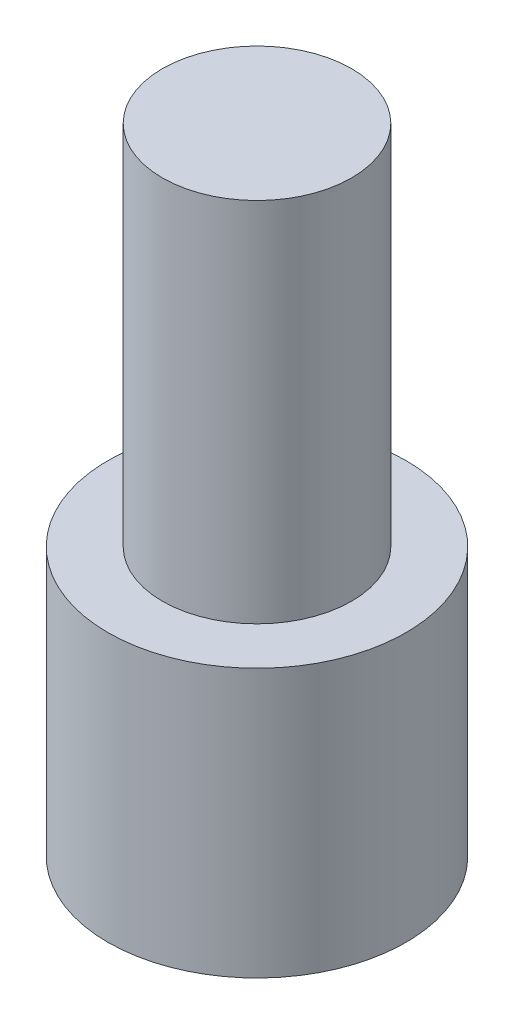
from build123d import *

# Parameters (mm, degrees)
SKETCH_1_R      = 5
EXTRUDE_1_DEPTH = 9
SKETCH_2_R      = 3.175
EXTRUDE_2_DEPTH = 12.3


with BuildPart() as part:
    # Эскиз1 → Бобышка-Вытянуть1 (new body)
    with BuildSketch(Plane(origin=(0, 0, 0), x_dir=(1, 0, 0), z_dir=(0, 1, 0))):
        Circle(SKETCH_1_R)
    extrude(amount=EXTRUDE_1_DEPTH)

    # Эскиз2 → Бобышка-Вытянуть2 (add)
    with BuildSketch(Plane(origin=(0, 9, 0), x_dir=(1, 0, 0), z_dir=(0, 1, 0))):
        Circle(SKETCH_2_R)
    extrude(amount=EXTRUDE_2_DEPTH)


solid = part.part
